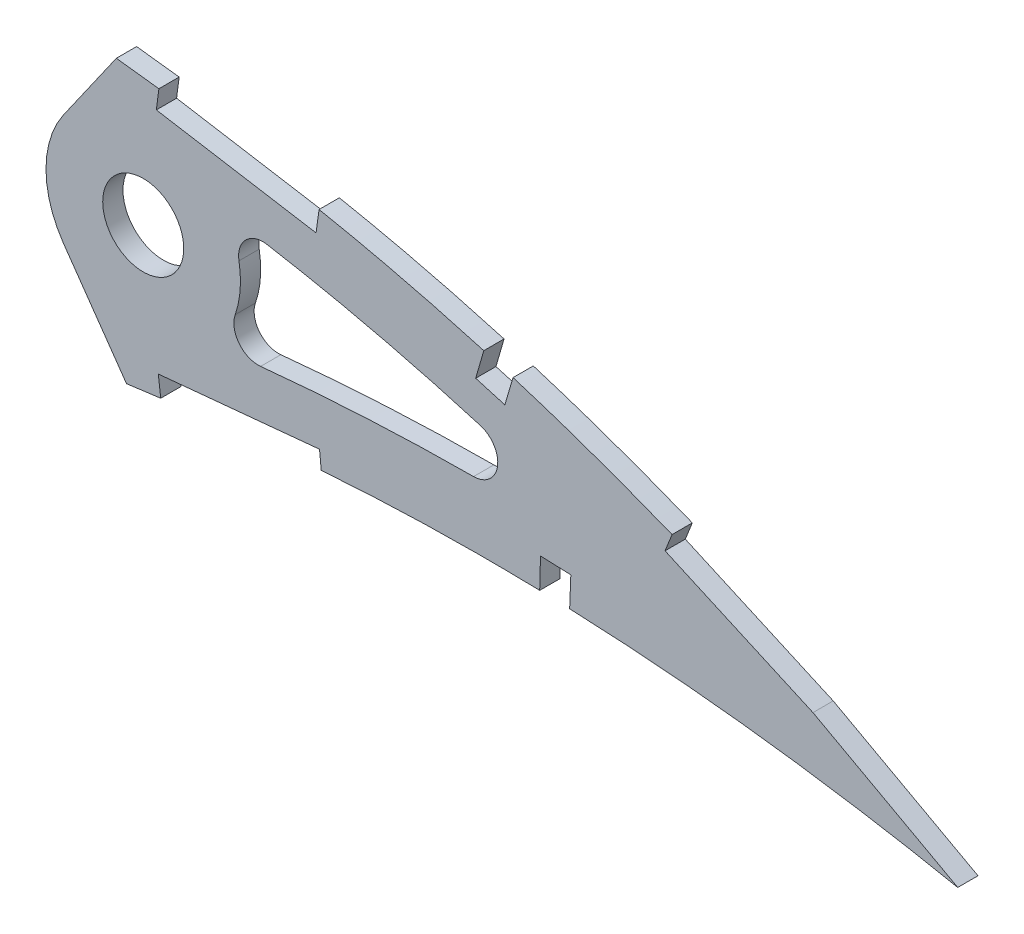
from build123d import *

# Parameters (mm, degrees)
BOSS_EXTRUDE1_DEPTH = 3.175
SKETCH3_R           = 6.35
CUT_EXTRUDE2_DEPTH  = 7.62
CUT_EXTRUDE3_DEPTH  = 425.770685521
CUT_EXTRUDE7_DEPTH  = 425.054471104
FILLET1_R           = 3.81


with BuildPart() as part:
    # Sketch1 → Boss-Extrude1 (new body)
    with BuildSketch(Plane.XY):
        with BuildLine():
            Line((417.491116248, -0.651692804), (421.450974812, -1.472467044))
            Line((421.450974812, -1.472467044), (418.012470552, 0.651692804))
            add(Edge.make_bspline(
                [(418.012470552, 0.651692804), (417.98044815, 0.671474864), (417.852482746, 0.75052638), (417.564153255, 0.927383578), (417.084024874, 1.221948394), (416.411887136, 1.63217468), (415.548261806, 2.156972941), (414.492714479, 2.792668486), (413.245904156, 3.537195961), (411.808132787, 4.387034494), (410.179547234, 5.338203991), (408.360768057, 6.386852134), (406.351953186, 7.52704122), (404.153880987, 8.754112876), (401.767305606, 10.062231026), (399.19267854, 11.445487716), (396.430921499, 12.896846477), (393.483094762, 14.410065077), (390.349735958, 15.976787411), (387.032322118, 17.590492828), (383.53195848, 19.243135295), (379.849840019, 20.925898146), (375.98808191, 22.631921026), (371.947751923, 24.35059805), (367.731152528, 26.074482818), (363.340078768, 27.793764201), (358.777130588, 29.500612257), (354.044068493, 31.183969527), (349.144430575, 32.836479872), (344.080593504, 34.447407706), (338.856178603, 36.008004406), (333.474221444, 37.508151761), (327.939208494, 38.940156234), (322.254650095, 40.293589254), (316.425364207, 41.559391603), (310.455984511, 42.72994226), (304.351517267, 43.793554912), (298.12887857, 44.749400354), (291.888189265, 45.544501897), (285.660339717, 46.324314327), (279.441765017, 47.05687676), (273.147186285, 47.758406613), (266.78265934, 48.424954116), (260.354497207, 49.054435041), (253.869207533, 49.644132572), (247.333529654, 50.192317352), (240.75378784, 50.695883209), (234.13692006, 51.154054264), (227.48946797, 51.562802699), (220.818511901, 51.921821557), (214.130823757, 52.228606963), (207.433363169, 52.481045058), (200.733241899, 52.677611966), (194.03741489, 52.816424499), (187.353132032, 52.896609907), (180.687346008, 52.915977167), (174.047303325, 52.874179852), (167.439957194, 52.769782806), (160.872561498, 52.601356868), (154.352078932, 52.36858769), (147.885560384, 52.071576223), (141.480086041, 51.707835252), (135.142604697, 51.279682727), (128.880173648, 50.78532016), (122.699673543, 50.224616012), (116.607581601, 49.599907517), (110.610680398, 48.90949561), (104.715396798, 48.155344678), (98.928179068, 47.338933301), (93.255520599, 46.45981687), (87.703498103, 45.520534547), (82.278103773, 44.522047456), (76.985077668, 43.467282827), (71.830182495, 42.356515787), (66.818874958, 41.193078409), (61.956363154, 39.97899758), (57.247874135, 38.716495991), (52.698180969, 37.408603084), (48.311884381, 36.058286041), (44.094097756, 34.667028605), (40.048008795, 33.240105797), (36.178587704, 31.778530584), (32.488798598, 30.286805616), (28.982965605, 28.766967771), (25.66370775, 27.223650228), (22.534781646, 25.658610062), (19.59841729, 24.076231981), (16.857562593, 22.478942324), (14.314855879, 20.869707996), (11.971365892, 19.2526108), (9.830323596, 17.628665848), (7.892464518, 16.001976699), (6.159015004, 14.37502038), (4.632452775, 12.748917707), (3.312722951, 11.12653219), (2.201555106, 9.509148701), (1.299141963, 7.898297704), (0.607524637, 6.295149332), (0.126017388, 4.70060514), (-0.137556514, 3.117018659), (-0.203161624, 1.54312034), (-0.067619355, 0.51360488), (0, 0)],
                knots=[0, 0, 0, 0, 0.00025409, 0.001015373, 0.002283359, 0.004056577, 0.006330981, 0.009105275, 0.01237449, 0.016134023, 0.020379661, 0.025105976, 0.030306237, 0.035972206, 0.042099523, 0.048678063, 0.055701664, 0.063160184, 0.071045824, 0.079349826, 0.08806291, 0.097175756, 0.106678112, 0.116561573, 0.126814275, 0.137428301, 0.148393618, 0.15969976, 0.171338125, 0.183297699, 0.195569604, 0.208143556, 0.221011593, 0.234161831, 0.24758745, 0.261276822, 0.27522271, 0.289414144, 0.3037712, 0.317689227, 0.331784111, 0.346039677, 0.36044387, 0.37498272, 0.389640454, 0.404403317, 0.419256601, 0.434186749, 0.449177265, 0.464214782, 0.479284009, 0.49436974, 0.509457833, 0.524532346, 0.53957932, 0.554582984, 0.569529546, 0.584403417, 0.599190992, 0.613876838, 0.628447475, 0.642888675, 0.657186054, 0.671325546, 0.685294014, 0.699078147, 0.712665095, 0.726042645, 0.739197713, 0.752117586, 0.764792042, 0.777208152, 0.789355685, 0.80122396, 0.812803686, 0.824082909, 0.835054602, 0.845709571, 0.856037853, 0.866033834, 0.875688843, 0.884997719, 0.893953426, 0.902552897, 0.910789386, 0.918660734, 0.926166253, 0.933302626, 0.94007122, 0.94647478, 0.952517526, 0.958204819, 0.963546652, 0.9685566, 0.973249913, 0.977651041, 0.981787043, 0.985694226, 0.989415109, 0.993001157, 0.996508416, 1, 1, 1, 1], degree=3))
            add(Edge.make_bspline(
                [(0, 0), (0.107344122, -0.506735851), (0.322525701, -1.522536416), (0.907145976, -2.98486836), (1.680278374, -4.390592942), (2.658149173, -5.735976229), (3.834256448, -7.020650547), (5.206002713, -8.245952015), (6.772042592, -9.411221952), (8.530326502, -10.515929932), (10.478300238, -11.56124868), (12.613774275, -12.546528288), (14.934801506, -13.471460836), (17.438853083, -14.334810006), (20.122867794, -15.137890506), (22.984293745, -15.87874546), (26.019877259, -16.558410209), (29.226698653, -17.175149915), (32.601263508, -17.729591078), (36.140066093, -18.221423529), (39.839474107, -18.650954746), (43.695858135, -19.017283569), (47.705403835, -19.321197808), (51.864114831, -19.562899166), (56.167954337, -19.743154049), (60.612799743, -19.861277173), (65.194297816, -19.919110149), (69.90830817, -19.917521134), (74.750219376, -19.856085207), (79.715895302, -19.738196204), (84.800570833, -19.563107476), (89.999655516, -19.33293774), (95.308459722, -19.050003416), (100.722222022, -18.715263595), (106.236178133, -18.330201822), (111.845540422, -17.897906181), (117.545213296, -17.419454845), (123.330225884, -16.897636702), (129.195456677, -16.33506396), (135.135838219, -15.733517171), (141.146127059, -15.095825988), (147.22096994, -14.424056849), (153.355199033, -13.721793599), (159.543210771, -12.990306925), (165.779772492, -12.233773195), (172.059017171, -11.453637843), (178.375694094, -10.652905812), (184.724121999, -9.835347203), (191.098357706, -9.000868908), (197.493040005, -8.155416157), (203.902002084, -7.29829268), (210.319665377, -6.433906623), (216.740089126, -5.564944849), (223.157019771, -4.691674703), (229.564816603, -3.817715282), (235.957535291, -2.945465763), (242.328914049, -2.075005893), (248.673188486, -1.210662101), (254.983970072, -0.352328891), (261.255439585, 0.498253703), (267.481587275, 1.33854664), (273.656539031, 2.167489343), (279.773925067, 2.98455751), (285.827590721, 3.790057847), (291.72081698, 4.559541474), (297.438204766, 5.333983617), (302.999020517, 5.96885451), (308.4905971, 6.510739718), (313.918638837, 6.955010775), (319.276627913, 7.30805944), (324.558425157, 7.572408429), (329.75773577, 7.751748326), (334.867992319, 7.851399579), (339.882811875, 7.873890942), (344.79534958, 7.826395206), (349.599216077, 7.712740899), (354.287706783, 7.538029372), (358.854280799, 7.308155071), (363.292451785, 7.029384641), (367.595556763, 6.705830062), (371.757599447, 6.34504489), (375.772158368, 5.952310734), (379.633069209, 5.532114413), (383.334698301, 5.093260959), (386.871120866, 4.638639591), (390.237017411, 4.175721536), (393.426969843, 3.709197789), (396.435926147, 3.245024667), (399.259158851, 2.787630174), (401.892107523, 2.343085233), (404.330647739, 1.915543252), (406.570547937, 1.509179531), (408.608700706, 1.129121201), (410.44108076, 0.777256216), (412.065237404, 0.459383467), (413.478150672, 0.176905414), (414.67774925, -0.066198026), (415.661938268, -0.268967448), (416.429222922, -0.428074261), (416.978087732, -0.54377272), (417.307939008, -0.612619163), (417.454496179, -0.643881356), (417.491116248, -0.651692804)],
                knots=[0, 0, 0, 0, 0.003638255, 0.007293231, 0.011028136, 0.014901081, 0.018963272, 0.023258475, 0.027820626, 0.032679082, 0.03785316, 0.043361875, 0.049214679, 0.055422346, 0.061988786, 0.068918036, 0.076211157, 0.083868392, 0.091887411, 0.100265912, 0.108999867, 0.118084529, 0.127514843, 0.13728527, 0.147387917, 0.157816481, 0.168563473, 0.179619128, 0.190977373, 0.202626974, 0.214560478, 0.226767249, 0.239236417, 0.251959004, 0.264923894, 0.278119703, 0.291536035, 0.30516028, 0.318980685, 0.332985499, 0.34716279, 0.361498603, 0.375980747, 0.390597192, 0.405332593, 0.420174823, 0.435109533, 0.450124276, 0.465203068, 0.480333154, 0.495500583, 0.510689775, 0.525887334, 0.541078314, 0.556247233, 0.571381784, 0.58646604, 0.601484516, 0.616424329, 0.631269422, 0.646006524, 0.660620684, 0.675098187, 0.689422858, 0.703581825, 0.716907563, 0.730009275, 0.742952128, 0.755725558, 0.768319952, 0.780724338, 0.792926529, 0.804916041, 0.816679084, 0.828203524, 0.8394749, 0.850481359, 0.861207697, 0.871639326, 0.881763414, 0.891563605, 0.901027365, 0.910138977, 0.918883977, 0.927249278, 0.935221104, 0.942784738, 0.949928188, 0.956638464, 0.962904203, 0.968712288, 0.974054485, 0.978918432, 0.983297218, 0.987180246, 0.990560674, 0.993433357, 0.995790625, 0.997629587, 0.998945816, 0.999736592, 1, 1, 1, 1], degree=3))
        make_face()
    extrude(amount=BOSS_EXTRUDE1_DEPTH)

    # Sketch3 → Cut-Extrude2 (cut)
    with BuildSketch(Plane(origin=(0, 0, 0), x_dir=(-1, 0, 0), z_dir=(0, 0, -1))):
        with Locations((-285.729166098, 26.255421435)):
            Circle(SKETCH3_R)
    extrude(amount=-CUT_EXTRUDE2_DEPTH, mode=Mode.SUBTRACT)

    # Sketch4 → Cut-Extrude3 (cut, through all)
    with BuildSketch(Plane.XY.offset(3.175)):
        with BuildLine():
            ThreePointArc((273.245288943, 17.514116545), (270.489166098, 26.255421435), (273.245288943, 34.996726325))
            Line((273.245288943, 34.996726325), (274.886273897, 37.340295715))
            Line((274.886273897, 37.340295715), (281.517132997, 46.810143922))
            add(Edge.make_bspline(
                [(281.517132997, 46.810143922), (280.833063767, 46.890035279), (278.05111843, 47.211864113), (273.147186285, 47.758406613), (266.78265934, 48.424954116), (260.354497207, 49.054435041), (253.869207533, 49.644132572), (247.333529654, 50.192317352), (240.75378784, 50.695883209), (234.13692006, 51.154054264), (227.48946797, 51.562802699), (220.818511901, 51.921821557), (214.130823757, 52.228606963), (207.433363169, 52.481045058), (200.733241899, 52.677611966), (194.03741489, 52.816424499), (187.353132032, 52.896609907), (180.687346008, 52.915977167), (174.047303325, 52.874179852), (167.439957194, 52.769782806), (160.872561498, 52.601356868), (155.481659891, 52.408911643), (152.280960421, 52.270445439), (151.253871268, 52.223436592)],
                knots=[0.32713491, 0.32713491, 0.32713491, 0.32713491, 0.331784111, 0.346039677, 0.36044387, 0.37498272, 0.389640454, 0.404403317, 0.419256601, 0.434186749, 0.449177265, 0.464214782, 0.479284009, 0.49436974, 0.509457833, 0.524532346, 0.53957932, 0.554582984, 0.569529546, 0.584403417, 0.599190992, 0.613876838, 0.620817468, 0.620817468, 0.620817468, 0.620817468], degree=3))
            add(Edge.make_bspline(
                [(151.253871268, 52.223436592), (150.124766545, 52.171758595), (146.859034641, 52.01328398), (141.480086041, 51.707835252), (135.142604697, 51.279682727), (128.880173648, 50.78532016), (122.699673543, 50.224616012), (116.607581601, 49.599907517), (110.610680398, 48.90949561), (104.715396798, 48.155344678), (98.928179068, 47.338933301), (93.255520599, 46.45981687), (87.703498103, 45.520534547), (82.278103773, 44.522047456), (76.985077668, 43.467282827), (71.830182495, 42.356515787), (66.818874958, 41.193078409), (61.956363154, 39.97899758), (57.247874135, 38.716495991), (52.698180969, 37.408603084), (48.311884381, 36.058286041), (44.094097756, 34.667028605), (40.048008795, 33.240105797), (36.178587704, 31.778530584), (32.488798598, 30.286805616), (28.982965605, 28.766967771), (25.66370775, 27.223650228), (22.534781646, 25.658610062), (19.59841729, 24.076231981), (16.857562593, 22.478942324), (14.314855879, 20.869707996), (11.971365892, 19.2526108), (9.830323596, 17.628665848), (7.892464518, 16.001976699), (6.159015004, 14.37502038), (4.632452775, 12.748917707), (3.312722951, 11.12653219), (2.201555106, 9.509148701), (1.299141963, 7.898297704), (0.607524637, 6.295149332), (0.126017388, 4.70060514), (-0.137556514, 3.117018659), (-0.203161624, 1.54312034), (-0.067619355, 0.51360488), (0, 0)],
                knots=[0.620817468, 0.620817468, 0.620817468, 0.620817468, 0.628447475, 0.642888675, 0.657186054, 0.671325546, 0.685294014, 0.699078147, 0.712665095, 0.726042645, 0.739197713, 0.752117586, 0.764792042, 0.777208152, 0.789355685, 0.80122396, 0.812803686, 0.824082909, 0.835054602, 0.845709571, 0.856037853, 0.866033834, 0.875688843, 0.884997719, 0.893953426, 0.902552897, 0.910789386, 0.918660734, 0.926166253, 0.933302626, 0.94007122, 0.94647478, 0.952517526, 0.958204819, 0.963546652, 0.9685566, 0.973249913, 0.977651041, 0.981787043, 0.985694226, 0.989415109, 0.993001157, 0.996508416, 1, 1, 1, 1], degree=3))
            add(Edge.make_bspline(
                [(0, 0), (0.107344122, -0.506735851), (0.322525701, -1.522536416), (0.907145976, -2.98486836), (1.680278374, -4.390592942), (2.658149173, -5.735976229), (3.834256448, -7.020650547), (5.206002713, -8.245952015), (6.772042592, -9.411221952), (8.530326502, -10.515929932), (10.478300238, -11.56124868), (12.613774275, -12.546528288), (14.934801506, -13.471460836), (17.438853083, -14.334810006), (20.122867794, -15.137890506), (22.984293745, -15.87874546), (26.019877259, -16.558410209), (29.226698653, -17.175149915), (32.601263508, -17.729591078), (36.140066093, -18.221423529), (39.839474107, -18.650954746), (43.695858135, -19.017283569), (47.705403835, -19.321197808), (51.864114831, -19.562899166), (56.167954337, -19.743154049), (60.612799743, -19.861277173), (65.194297816, -19.919110149), (69.90830817, -19.917521134), (74.750219376, -19.856085207), (79.715895302, -19.738196204), (84.800570833, -19.563107476), (89.999655516, -19.33293774), (95.308459722, -19.050003416), (100.722222022, -18.715263595), (106.236178133, -18.330201822), (111.845540422, -17.897906181), (117.545213296, -17.419454845), (123.330225884, -16.897636702), (129.195456677, -16.33506396), (135.135838219, -15.733517171), (141.146127059, -15.095825988), (147.22096994, -14.424056849), (153.355199033, -13.721793599), (159.543210771, -12.990306925), (165.779772492, -12.233773195), (172.059017171, -11.453637843), (176.943047577, -10.834514903), (179.733508183, -10.477064851), (180.418148813, -10.389136696)],
                knots=[0, 0, 0, 0, 0.003638255, 0.007293231, 0.011028136, 0.014901081, 0.018963272, 0.023258475, 0.027820626, 0.032679082, 0.03785316, 0.043361875, 0.049214679, 0.055422346, 0.061988786, 0.068918036, 0.076211157, 0.083868392, 0.091887411, 0.100265912, 0.108999867, 0.118084529, 0.127514843, 0.13728527, 0.147387917, 0.157816481, 0.168563473, 0.179619128, 0.190977373, 0.202626974, 0.214560478, 0.226767249, 0.239236417, 0.251959004, 0.264923894, 0.278119703, 0.291536035, 0.30516028, 0.318980685, 0.332985499, 0.34716279, 0.361498603, 0.375980747, 0.390597192, 0.405332593, 0.420174823, 0.435109533, 0.439965351, 0.439965351, 0.439965351, 0.439965351], degree=3))
            add(Edge.make_bspline(
                [(180.418148813, -10.389136696), (181.850495116, -10.205180963), (185.408545914, -9.745746359), (191.098357706, -9.000868908), (197.493040005, -8.155416157), (203.902002084, -7.29829268), (210.319665377, -6.433906623), (216.740089126, -5.564944849), (223.157019771, -4.691674703), (229.564816603, -3.817715282), (235.957535291, -2.945465763), (242.328914049, -2.075005893), (248.673188486, -1.210662101), (254.983970072, -0.352328891), (261.255439585, 0.498253703), (267.481587275, 1.33854664), (273.656539031, 2.167489343), (278.85986366, 2.862470972), (282.004212477, 3.281215433), (283.108625896, 3.427811537)],
                knots=[0.439965351, 0.439965351, 0.439965351, 0.439965351, 0.450124276, 0.465203068, 0.480333154, 0.495500583, 0.510689775, 0.525887334, 0.541078314, 0.556247233, 0.571381784, 0.58646604, 0.601484516, 0.616424329, 0.631269422, 0.646006524, 0.660620684, 0.675098187, 0.682935578, 0.682935578, 0.682935578, 0.682935578], degree=3))
            Line((283.108625896, 3.427811537), (276.543076139, 12.804388335))
            Line((276.543076139, 12.804388335), (273.245288943, 17.514116545))
        make_face()
        with BuildLine():
            add(Edge.make_bspline(
                [(362.352770137, 17.265342245), (359.116729683, 18.538986422), (350.651628268, 21.70312526), (336.76245738, 26.184380092), (323.325821889, 29.685457962), (312.46520361, 32.017125458), (305.650127669, 33.271885786), (301.010448964, 34.024743586), (299.133105649, 34.309199759), (298.619492426, 34.385432945)],
                knots=[0.130937261, 0.130937261, 0.130937261, 0.130937261, 0.155204367, 0.194005459, 0.23280655, 0.252207096, 0.271607642, 0.281307915, 0.284959903, 0.284959903, 0.284959903, 0.284959903], degree=3))
            ThreePointArc((298.619492426, 34.385432945), (300.369968215, 30.486793952), (300.969166098, 26.255421435))
            ThreePointArc((300.969166098, 26.255421435), (299.795673281, 20.391039483), (296.455914698, 15.429782217))
            add(Edge.make_bspline(
                [(296.455914698, 15.429782217), (296.825227638, 15.475634747), (298.474939021, 15.677515554), (301.393417945, 16.007171577), (306.480644201, 16.530089608), (315.428804381, 17.299112469), (328.220882032, 17.971225759), (343.594122404, 18.103863059), (354.969060254, 17.713169544), (361.214906663, 17.338809272), (362.352770137, 17.265342245)],
                knots=[0.717454935, 0.717454935, 0.717454935, 0.717454935, 0.719982675, 0.728733217, 0.737483758, 0.754984841, 0.789987006, 0.824989172, 0.859991338, 0.867792259, 0.867792259, 0.867792259, 0.867792259], degree=3))
        make_face()
    extrude(amount=-CUT_EXTRUDE3_DEPTH, mode=Mode.SUBTRACT)

    # Sketch5 → Cut-Extrude7 (cut, through all)
    with BuildSketch(Plane.XY.offset(3.175)):
        with BuildLine():
            Line((312.821335019, 38.753562426), (313.255170713, 41.898687323))
            Line((313.255170713, 41.898687323), (289.899067063, 45.792621006))
            add(Edge.make_bspline(
                [(289.899067063, 45.792621006), (289.327695014, 45.86424804), (288.756288707, 45.935576746), (288.18483278, 46.006492863)],
                knots=[0.308135501, 0.308135501, 0.308135501, 0.308135501, 0.312022743, 0.312022743, 0.312022743, 0.312022743], degree=3))
            Line((288.18483278, 46.006492863), (287.782761512, 42.929129605))
            Line((287.782761512, 42.929129605), (312.821335019, 38.753562426))
        make_face()
        with BuildLine():
            add(Edge.make_bspline(
                [(343.696889212, 34.548804769), (342.172537383, 35.016658738), (340.644496896, 35.472496268), (339.112914588, 35.916106743)],
                knots=[0.18429409, 0.18429409, 0.18429409, 0.18429409, 0.195057897, 0.195057897, 0.195057897, 0.195057897], degree=3))
            Line((339.112914588, 35.916106743), (337.842050201, 31.532458076))
            Line((337.842050201, 31.532458076), (342.415698461, 30.206510868))
            Line((342.415698461, 30.206510868), (343.696889212, 34.548804769))
        make_face()
        with BuildLine():
            Line((288.090829112, 7.230307071), (288.473233128, 4.135484924))
            add(Edge.make_bspline(
                [(288.473233128, 4.135484924), (289.594788858, 4.28290658), (292.594382973, 4.677869344), (297.438204766, 5.333983617), (302.999020517, 5.96885451), (308.385529955, 6.500372143), (311.923755316, 6.7916837), (313.629213194, 6.919156546)],
                knots=[0.695624101, 0.695624101, 0.695624101, 0.695624101, 0.703581825, 0.716907563, 0.730009275, 0.742952128, 0.754982876, 0.754982876, 0.754982876, 0.754982876], degree=3))
            Line((313.629213194, 6.919156546), (313.365737121, 9.657196477))
            Line((313.365737121, 9.657196477), (288.090829112, 7.230307071))
        make_face()
        with BuildLine():
            Line((347.998810678, 12.491057018), (347.875803206, 7.750166764))
            add(Edge.make_bspline(
                [(347.875803206, 7.750166764), (348.462751791, 7.735204441), (350.028274887, 7.691340521), (351.593475711, 7.636954078), (352.571728026, 7.598887347)],
                knots=[0.835344568, 0.835344568, 0.835344568, 0.835344568, 0.8394749, 0.846361798, 0.846361798, 0.846361798, 0.846361798], degree=3))
            Line((352.571728026, 7.598887347), (352.756830462, 12.303809245))
            Line((352.756830462, 12.303809245), (347.998810678, 12.491057018))
        make_face()
        with BuildLine():
            Line((289.899067063, 45.792621006), (313.255170713, 41.898687323))
            Line((313.255170713, 41.898687323), (313.29236598, 42.168337243))
            add(Edge.make_bspline(
                [(313.29236598, 42.168337243), (312.358922935, 42.350690786), (309.395078462, 42.914789365), (304.351517267, 43.793554912), (298.12887857, 44.749400354), (293.292161985, 45.365627285), (290.540560467, 45.712203579), (289.899067063, 45.792621006)],
                knots=[0.254856585, 0.254856585, 0.254856585, 0.254856585, 0.261276822, 0.27522271, 0.289414144, 0.3037712, 0.308135501, 0.308135501, 0.308135501, 0.308135501], degree=3))
        make_face()
        with BuildLine():
            add(Edge.make_bspline(
                [(377.634130938, 21.901933297), (377.102042762, 22.136216112), (375.227723696, 22.955362477), (372.227993036, 24.231388984), (369.750213277, 25.248550826), (368.624234459, 25.703125603)],
                knots=[0.102753492, 0.102753492, 0.102753492, 0.102753492, 0.106678112, 0.116561573, 0.12475852, 0.12475852, 0.12475852, 0.12475852], degree=3))
            Line((368.624234459, 25.703125603), (367.524948991, 22.947437951))
            Line((367.524948991, 22.947437951), (390.709870237, 12.581708749))
            Line((390.709870237, 12.581708749), (413.003167342, 0.410595518))
            Line((413.003167342, 0.410595518), (414.349871495, 2.877294762))
            add(Edge.make_bspline(
                [(414.349871495, 2.877294762), (414.002853317, 3.085155075), (413.177223506, 3.57779175), (411.808132787, 4.387034494), (410.179547234, 5.338203991), (408.360768057, 6.386852134), (406.351953186, 7.52704122), (404.153880987, 8.754112876), (401.767305606, 10.062231026), (399.19267854, 11.445487716), (396.430921499, 12.896846477), (393.483094762, 14.410065077), (390.349735958, 15.976787411), (387.032322118, 17.590492828), (383.883707289, 19.077062543), (381.837430118, 20.016767057), (380.962359367, 20.413918123)],
                knots=[0.009643839, 0.009643839, 0.009643839, 0.009643839, 0.01237449, 0.016134023, 0.020379661, 0.025105976, 0.030306237, 0.035972206, 0.042099523, 0.048678063, 0.055701664, 0.063160184, 0.071045824, 0.079349826, 0.08806291, 0.09454998, 0.09454998, 0.09454998, 0.09454998], degree=3))
            Line((380.962359367, 20.413918123), (377.634130938, 21.901933297))
        make_face()
        with BuildLine():
            Line((414.349871495, 2.877294762), (413.003167342, 0.410595518))
            Line((413.003167342, 0.410595518), (413.405544087, 0.190916352))
            add(Edge.make_bspline(
                [(413.405544087, 0.190916352), (413.453295022, 0.18131381), (413.901375593, 0.091137194), (414.67774925, -0.066198026), (415.661938268, -0.268967448), (416.429222922, -0.428074261), (416.978087732, -0.54377272), (417.307939008, -0.612619163), (417.454496179, -0.643881356), (417.491116248, -0.651692804)],
                knots=[0.990218035, 0.990218035, 0.990218035, 0.990218035, 0.990560674, 0.993433357, 0.995790625, 0.997629587, 0.998945816, 0.999736592, 1, 1, 1, 1], degree=3))
            Line((417.491116248, -0.651692804), (421.450974812, -1.472467044))
            Line((421.450974812, -1.472467044), (418.012470552, 0.651692804))
            add(Edge.make_bspline(
                [(418.012470552, 0.651692804), (417.98044815, 0.671474864), (417.852482746, 0.75052638), (417.564153255, 0.927383578), (417.084024874, 1.221948394), (416.411887136, 1.63217468), (415.548261806, 2.156972941), (414.83923547, 2.583978791), (414.418313623, 2.836298632), (414.349871495, 2.877294762)],
                knots=[0, 0, 0, 0, 0.00025409, 0.001015373, 0.002283359, 0.004056577, 0.006330981, 0.009105275, 0.009643839, 0.009643839, 0.009643839, 0.009643839], degree=3))
        make_face()
        with BuildLine():
            Line((370.43491256, 29.773811487), (368.70109438, 25.89579797))
            Line((368.70109438, 25.89579797), (377.634130938, 21.901933297))
            add(Edge.make_bspline(
                [(380.962359367, 20.413918123), (380.608156259, 20.574673287), (379.500641935, 21.074915675), (378.390343517, 21.568966658), (377.634130938, 21.901933297)],
                knots=[0.09454998, 0.09454998, 0.09454998, 0.09454998, 0.097175756, 0.102753492, 0.102753492, 0.102753492, 0.102753492], degree=3))
            add(Edge.make_bspline(
                [(414.349871495, 2.877294762), (414.002853317, 3.085155075), (413.177223506, 3.57779175), (411.808132787, 4.387034494), (410.179547234, 5.338203991), (408.360768057, 6.386852134), (406.351953186, 7.52704122), (404.153880987, 8.754112876), (401.767305606, 10.062231026), (399.19267854, 11.445487716), (396.430921499, 12.896846477), (393.483094762, 14.410065077), (390.349735958, 15.976787411), (387.032322118, 17.590492828), (383.883707289, 19.077062543), (381.837430118, 20.016767057), (380.962359367, 20.413918123)],
                knots=[0.009643839, 0.009643839, 0.009643839, 0.009643839, 0.01237449, 0.016134023, 0.020379661, 0.025105976, 0.030306237, 0.035972206, 0.042099523, 0.048678063, 0.055701664, 0.063160184, 0.071045824, 0.079349826, 0.08806291, 0.09454998, 0.09454998, 0.09454998, 0.09454998], degree=3))
            add(Edge.make_bspline(
                [(418.012470552, 0.651692804), (417.98044815, 0.671474864), (417.852482746, 0.75052638), (417.564153255, 0.927383578), (417.084024874, 1.221948394), (416.411887136, 1.63217468), (415.548261806, 2.156972941), (414.83923547, 2.583978791), (414.418313623, 2.836298632), (414.349871495, 2.877294762)],
                knots=[0, 0, 0, 0, 0.00025409, 0.001015373, 0.002283359, 0.004056577, 0.006330981, 0.009105275, 0.009643839, 0.009643839, 0.009643839, 0.009643839], degree=3))
            Line((418.012470552, 0.651692804), (421.450974812, -1.472467044))
            Line((421.450974812, -1.472467044), (417.491116248, -0.651692804))
            add(Edge.make_bspline(
                [(413.405544087, 0.190916352), (413.453295022, 0.18131381), (413.901375593, 0.091137194), (414.67774925, -0.066198026), (415.661938268, -0.268967448), (416.429222922, -0.428074261), (416.978087732, -0.54377272), (417.307939008, -0.612619163), (417.454496179, -0.643881356), (417.491116248, -0.651692804)],
                knots=[0.990218035, 0.990218035, 0.990218035, 0.990218035, 0.990560674, 0.993433357, 0.995790625, 0.997629587, 0.998945816, 0.999736592, 1, 1, 1, 1], degree=3))
            Line((413.405544087, 0.190916352), (442.53165529, -15.710598609))
            Line((442.53165529, -15.710598609), (442.53165529, 29.773811487))
            Line((442.53165529, 29.773811487), (370.43491256, 29.773811487))
        make_face()
        with BuildLine():
            Line((368.70109438, 25.89579797), (368.624234459, 25.703125603))
            add(Edge.make_bspline(
                [(377.634130938, 21.901933297), (377.102042762, 22.136216112), (375.227723696, 22.955362477), (372.227993036, 24.231388984), (369.750213277, 25.248550826), (368.624234459, 25.703125603)],
                knots=[0.102753492, 0.102753492, 0.102753492, 0.102753492, 0.106678112, 0.116561573, 0.12475852, 0.12475852, 0.12475852, 0.12475852], degree=3))
            Line((377.634130938, 21.901933297), (368.70109438, 25.89579797))
        make_face()
    extrude(amount=-CUT_EXTRUDE7_DEPTH, mode=Mode.SUBTRACT)


with BuildPart() as body_2:
    # of the pieces the cut leaves, the one that is kept (cut_extrude7_keep)
    add(part.part.solids().sort_by_distance((352.571728026, 7.598887347, 0))[0])

    # Fillet1
    fillet1_edges = [body_2.edges().sort_by_distance(p)[0] for p in [
        (362.352770137, 17.265342245, 1.5875),
        (298.619492426, 34.385432945, 1.5875),
        (296.455914698, 15.429782217, 1.5875),
    ]]
    fillet(fillet1_edges, radius=FILLET1_R)


solid = body_2.part
